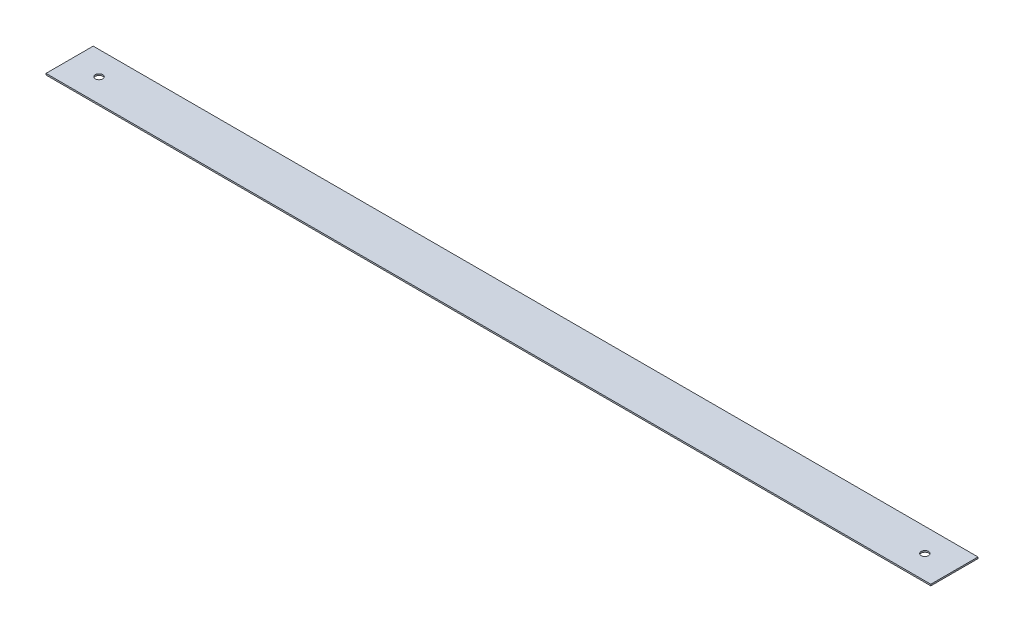
from build123d import *

# Parameters (mm, degrees)
SKETCH1_W           = 7620
SKETCH1_H           = 406.4
SKETCH1_R           = 31.75
BOSS_EXTRUDE1_DEPTH = 12.7


with BuildPart() as part:
    # Sketch1 → Boss-Extrude1 (new body)
    with BuildSketch(Plane(origin=(0, 0, 0), x_dir=(1, 0, 0), z_dir=(0, 1, 0))):
        with Locations((3810, -203.2)):
            Rectangle(SKETCH1_W, SKETCH1_H)
        with Locations((254, -203.2)):
            Circle(SKETCH1_R, mode=Mode.SUBTRACT)
        with Locations((7366, -203.2)):
            Circle(SKETCH1_R, mode=Mode.SUBTRACT)
    extrude(amount=BOSS_EXTRUDE1_DEPTH)


solid = part.part
